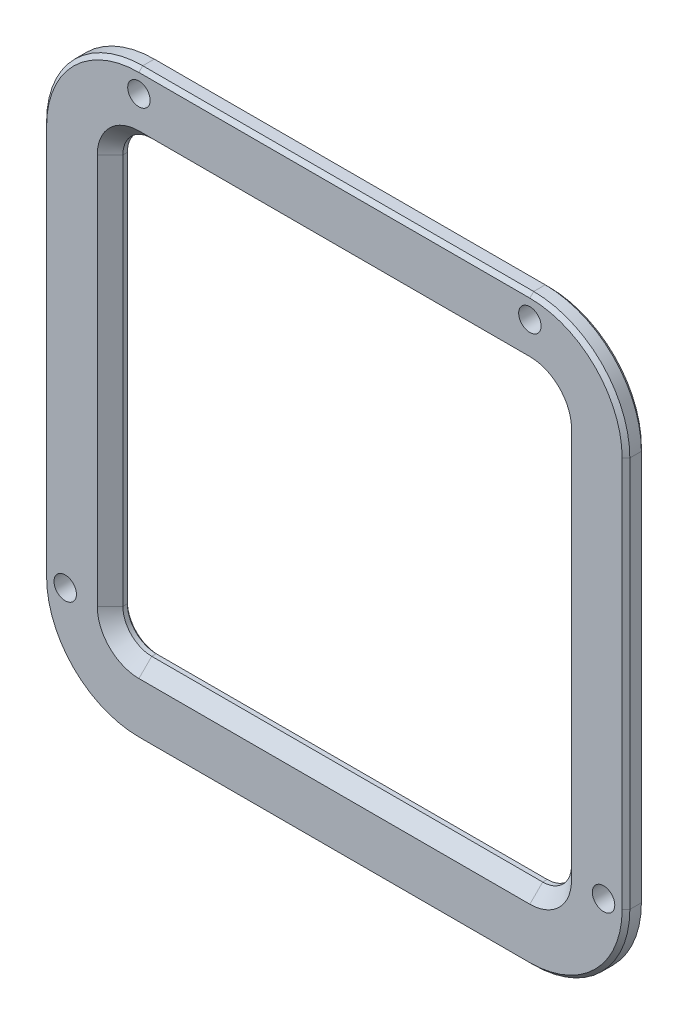
from build123d import *

# Parameters (mm, degrees)
SKETCH2_R           = 1.25
BOSS_EXTRUDE1_DEPTH = 3
CHAMFER1_SIZE       = 2
CHAMFER2_SIZE       = 0.6
CHAMFER3_SIZE       = 0.3
SKETCH3_R           = 1.75
CUT_EXTRUDE1_DEPTH  = 4


with BuildPart() as part:
    # Sketch2 → Boss-Extrude1 (new body)
    with BuildSketch(Plane.XY):
        with BuildLine():
            Line((-44.219607843, -34.337254902), (-44.219607843, 26.662745098))
            ThreePointArc((-44.219607843, 26.662745098), (-39.826209561, 37.269346816), (-29.219607843, 41.662745098))
            Line((-29.219607843, 41.662745098), (31.780392157, 41.662745098))
            ThreePointArc((31.780392157, 41.662745098), (42.386993875, 37.269346816), (46.780392157, 26.662745098))
            Line((46.780392157, 26.662745098), (46.780392157, -34.337254902))
            ThreePointArc((46.780392157, -34.337254902), (42.386993875, -44.94385662), (31.780392157, -49.337254902))
            Line((31.780392157, -49.337254902), (-29.219607843, -49.337254902))
            ThreePointArc((-29.219607843, -49.337254902), (-39.826209561, -44.94385662), (-44.219607843, -34.337254902))
        make_face()
        with Locations((43.280392157, -34.337254902)):
            Circle(SKETCH2_R, mode=Mode.SUBTRACT)
        with Locations((31.780392157, 38.162745098)):
            Circle(SKETCH2_R, mode=Mode.SUBTRACT)
        with Locations((-29.219607843, 38.162745098)):
            Circle(SKETCH2_R, mode=Mode.SUBTRACT)
        with Locations((-40.719607843, -34.337254902)):
            Circle(SKETCH2_R, mode=Mode.SUBTRACT)
        with BuildLine():
            ThreePointArc((-29.219607843, 31.162745098), (-32.401588358, 29.844725613), (-33.719607843, 26.662745098))
            Line((-33.719607843, 26.662745098), (-33.719607843, -34.337254902))
            ThreePointArc((-33.719607843, -34.337254902), (-32.401588358, -37.519235417), (-29.219607843, -38.837254902))
            Line((-29.219607843, -38.837254902), (31.780392157, -38.837254902))
            ThreePointArc((31.780392157, -38.837254902), (34.962372672, -37.519235417), (36.280392157, -34.337254902))
            Line((36.280392157, -34.337254902), (36.280392157, 26.662745098))
            ThreePointArc((36.280392157, 26.662745098), (34.962372672, 29.844725613), (31.780392157, 31.162745098))
            Line((31.780392157, 31.162745098), (-29.219607843, 31.162745098))
        make_face(mode=Mode.SUBTRACT)
    extrude(amount=BOSS_EXTRUDE1_DEPTH)

    # Chamfer1
    chamfer1_edges = [part.edges().sort_by_distance(p)[0] for p in [
        (-32.401588358, 29.844725613, 3),
        (1.280392157, 31.162745098, 3),
        (34.962372672, 29.844725613, 3),
        (36.280392157, -3.837254902, 3),
        (34.962372672, -37.519235417, 3),
        (1.280392157, -38.837254902, 3),
        (-32.401588358, -37.519235417, 3),
        (-33.719607843, -3.837254902, 3),
    ]]
    chamfer(chamfer1_edges, length=CHAMFER1_SIZE)

    # Chamfer2
    chamfer2_edges = [part.edges().sort_by_distance(p)[0] for p in [
        (1.280392157, 41.662745098, 3),
        (-39.826209561, 37.269346816, 3),
        (-39.826209561, 37.269346816, 0),
        (1.280392157, 41.662745098, 0),
        (42.386993875, 37.269346816, 0),
        (46.780392157, -3.837254902, 0),
        (42.386993875, -44.94385662, 0),
        (1.280392157, -49.337254902, 0),
        (-39.826209561, -44.94385662, 0),
        (-44.219607843, -3.837254902, 0),
        (-44.219607843, -3.837254902, 3),
        (-39.826209561, -44.94385662, 3),
        (1.280392157, -49.337254902, 3),
        (42.386993875, -44.94385662, 3),
        (46.780392157, -3.837254902, 3),
        (42.386993875, 37.269346816, 3),
    ]]
    chamfer(chamfer2_edges, length=CHAMFER2_SIZE)

    # Chamfer3
    chamfer3_edges = [part.edges().sort_by_distance(p)[0] for p in [
        (-33.719607843, -3.837254902, 0),
        (-32.401588358, -37.519235417, 0),
        (1.280392157, -38.837254902, 0),
        (34.962372672, -37.519235417, 0),
        (36.280392157, -3.837254902, 0),
        (34.962372672, 29.844725613, 0),
        (1.280392157, 31.162745098, 0),
        (-32.401588358, 29.844725613, 0),
    ]]
    chamfer(chamfer3_edges, length=CHAMFER3_SIZE)

    # Sketch3 → Cut-Extrude1 (cut, through all)
    with BuildSketch(Plane.XY.offset(3)):
        with Locations((-29.219607843, 38.162745098)):
            Circle(SKETCH3_R)
        with Locations((31.780392157, 38.162745098)):
            Circle(SKETCH3_R)
        with Locations((-40.719607843, -34.337254902)):
            Circle(SKETCH3_R)
        with Locations((43.280392157, -34.337254902)):
            Circle(SKETCH3_R)
    extrude(amount=-CUT_EXTRUDE1_DEPTH, mode=Mode.SUBTRACT)


solid = part.part
